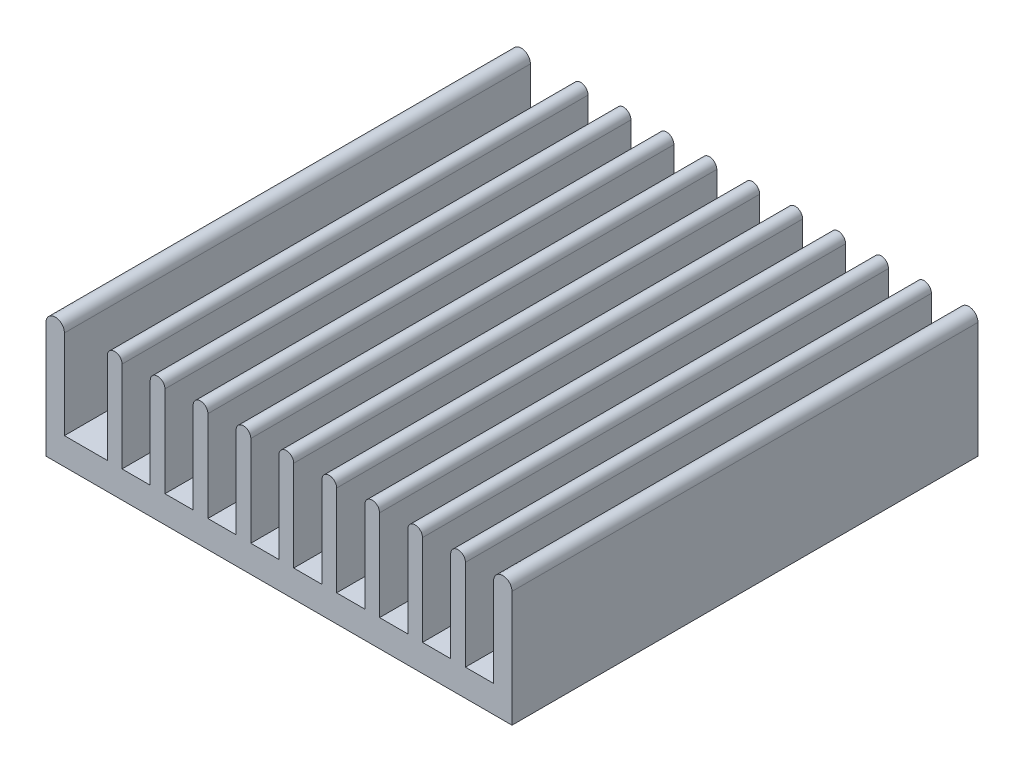
from build123d import *

# Parameters (mm, degrees)
EXTRUDE1_DEPTH = 38


with BuildPart() as part:
    # Sketch1 → Extrude1 (new body)
    with BuildSketch(Plane.XY):
        with BuildLine():
            Line((-19, 0), (19, 0))
            Line((19, 0), (19, 2.2))
            Line((19, 2.2), (19, 9.45))
            ThreePointArc((19, 9.45), (18.25, 10.2), (17.5, 9.45))
            Line((17.5, 9.45), (17.5, 2.2))
            Line((17.5, 2.2), (15.2, 2.2))
            Line((15.2, 2.2), (15.2, 9.6))
            ThreePointArc((15.2, 9.6), (14.6, 10.2), (14, 9.6))
            Line((14, 9.6), (14, 2.2))
            Line((14, 2.2), (11.7, 2.2))
            Line((11.7, 2.2), (11.7, 9.6))
            ThreePointArc((11.7, 9.6), (11.1, 10.2), (10.5, 9.6))
            Line((10.5, 9.6), (10.5, 2.2))
            Line((10.5, 2.2), (8.2, 2.2))
            Line((8.2, 2.2), (8.2, 9.6))
            ThreePointArc((8.2, 9.6), (7.6, 10.2), (7, 9.6))
            Line((7, 9.6), (7, 2.2))
            Line((7, 2.2), (4.7, 2.2))
            Line((4.7, 2.2), (4.7, 9.6))
            ThreePointArc((4.7, 9.6), (4.1, 10.2), (3.5, 9.6))
            Line((3.5, 9.6), (3.5, 2.2))
            Line((3.5, 2.2), (1.2, 2.2))
            Line((1.2, 2.2), (1.2, 9.6))
            ThreePointArc((1.2, 9.6), (0.6, 10.2), (0, 9.6))
            Line((0, 9.6), (0, 2.2))
            Line((0, 2.2), (-2.3, 2.2))
            Line((-2.3, 2.2), (-2.3, 9.6))
            ThreePointArc((-2.3, 9.6), (-2.9, 10.2), (-3.5, 9.6))
            Line((-3.5, 9.6), (-3.5, 2.2))
            Line((-3.5, 2.2), (-5.8, 2.2))
            Line((-5.8, 2.2), (-5.8, 9.6))
            ThreePointArc((-5.8, 9.6), (-6.4, 10.2), (-7, 9.6))
            Line((-7, 9.6), (-7, 2.2))
            Line((-7, 2.2), (-9.3, 2.2))
            Line((-9.3, 2.2), (-9.3, 9.6))
            ThreePointArc((-9.3, 9.6), (-9.9, 10.2), (-10.5, 9.6))
            Line((-10.5, 9.6), (-10.5, 2.2))
            Line((-10.5, 2.2), (-12.8, 2.2))
            Line((-12.8, 2.2), (-12.8, 9.6))
            ThreePointArc((-12.8, 9.6), (-13.4, 10.2), (-14, 9.6))
            Line((-14, 9.6), (-14, 2.2))
            Line((-14, 2.2), (-17.5, 2.2))
            Line((-17.5, 2.2), (-17.5, 9.45))
            ThreePointArc((-17.5, 9.45), (-18.25, 10.2), (-19, 9.45))
            Line((-19, 9.45), (-19, 2.2))
            Line((-19, 2.2), (-19, 0))
        make_face()
    extrude(amount=EXTRUDE1_DEPTH)


solid = part.part
